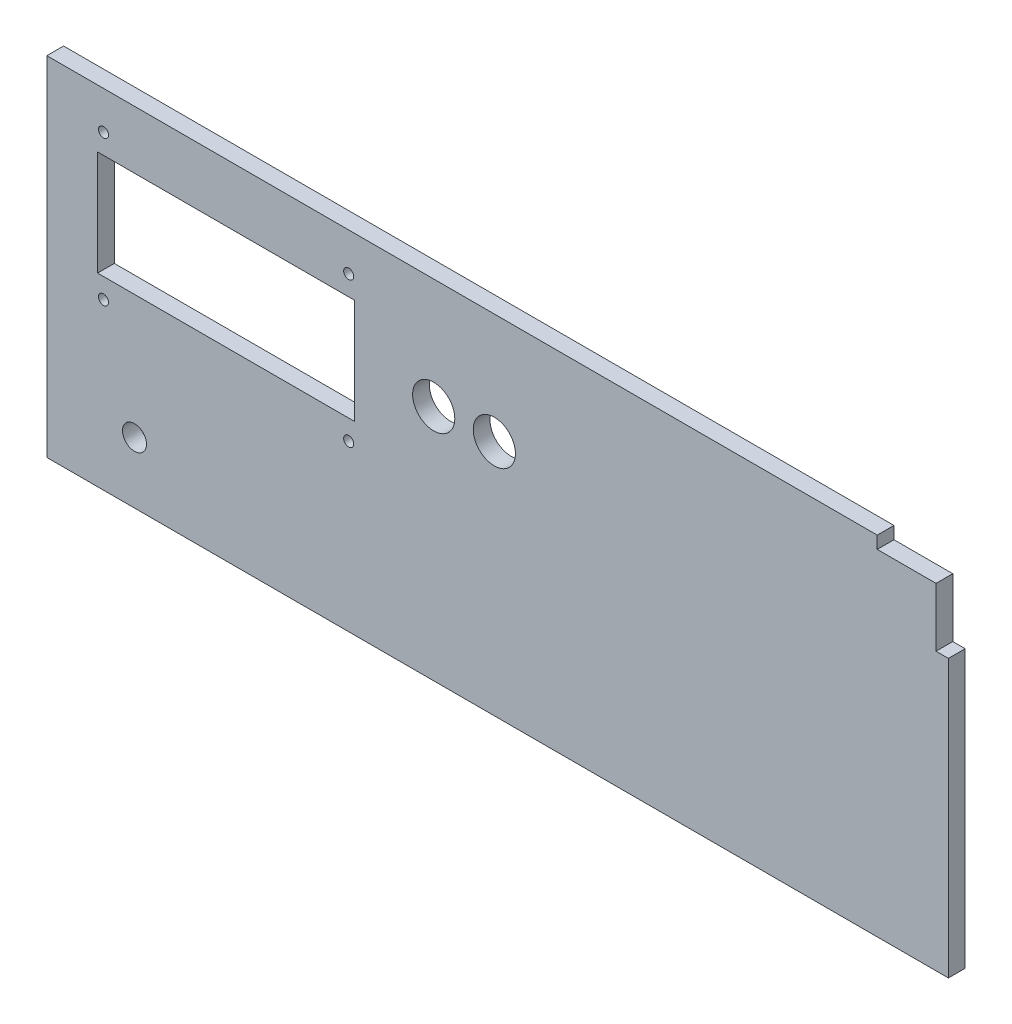
from build123d import *

# Parameters (mm, degrees)
SKETCH1_R           = 1.9
SKETCH1_R_2         = 8
SKETCH1_R_3         = 4.55
SKETCH1_W           = 97.5
SKETCH1_H           = 39.8
BOSS_EXTRUDE1_DEPTH = 6.35


with BuildPart() as part:
    # Sketch1 → Boss-Extrude1 (new body)
    with BuildSketch(Plane.XY):
        Polygon((0, 0), (342, 0), (342, 105), (337.3, 105), (337.3, 127.3), (315, 127.3), (315, 132), (0, 132), align=None)
        with Locations((114.499995121, 117.600002885)):
            Circle(SKETCH1_R, mode=Mode.SUBTRACT)
        with Locations((114.499995121, 62.6)):
            Circle(SKETCH1_R, mode=Mode.SUBTRACT)
        with Locations((21.499995121, 62.6)):
            Circle(SKETCH1_R, mode=Mode.SUBTRACT)
        with Locations((21.499995121, 117.600002885)):
            Circle(SKETCH1_R, mode=Mode.SUBTRACT)
        with Locations((146.75, 90.1)):
            Circle(SKETCH1_R_2, mode=Mode.SUBTRACT)
        with Locations((169.75, 90.1)):
            Circle(SKETCH1_R_2, mode=Mode.SUBTRACT)
        with Locations((33.25, 23.2)):
            Circle(SKETCH1_R_3, mode=Mode.SUBTRACT)
        with Locations((68, 90.1)):
            Rectangle(SKETCH1_W, SKETCH1_H, mode=Mode.SUBTRACT)
    extrude(amount=BOSS_EXTRUDE1_DEPTH)


solid = part.part
